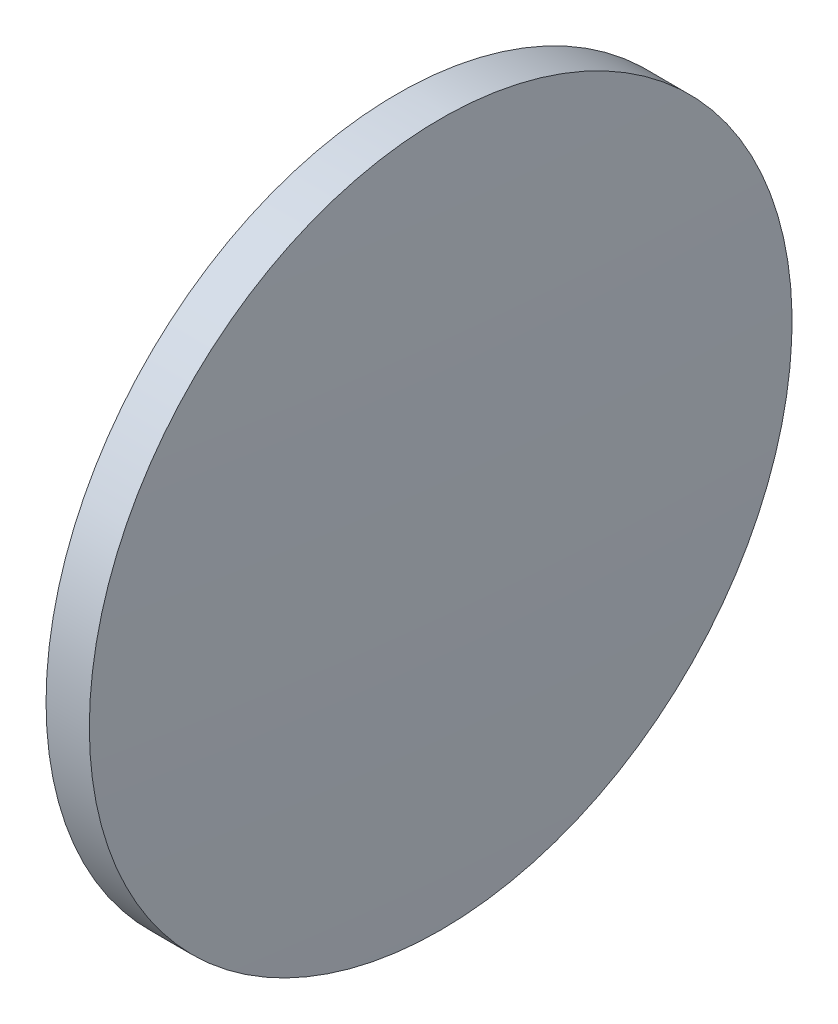
from build123d import *


with BuildPart() as part:
    # 草图1 → 旋转1 (revolve)
    with BuildSketch(Plane.XY, mode=Mode.PRIVATE) as revolve_1_sk:
        with BuildLine():
            Line((382.926336405, -40.400340366), (382.926336405, -27.900340366))
            Line((382.926336405, -27.900340366), (384.466336405, -27.900340366))
            ThreePointArc((384.466336405, -27.900340366), (384.646330876, -34.149188473), (384.706336405, -40.400340366))
            Line((384.706336405, -40.400340366), (382.926336405, -40.400340366))
        make_face()
    revolve(revolve_1_sk.sketch.rotate(Axis((380.897228826, -40.400340366, 0), (1, 0, 0)), 180), axis=Axis((380.897228826, -40.400340366, 0), (1, 0, 0)))  # turned: the seam where the file's is


solid = part.part
